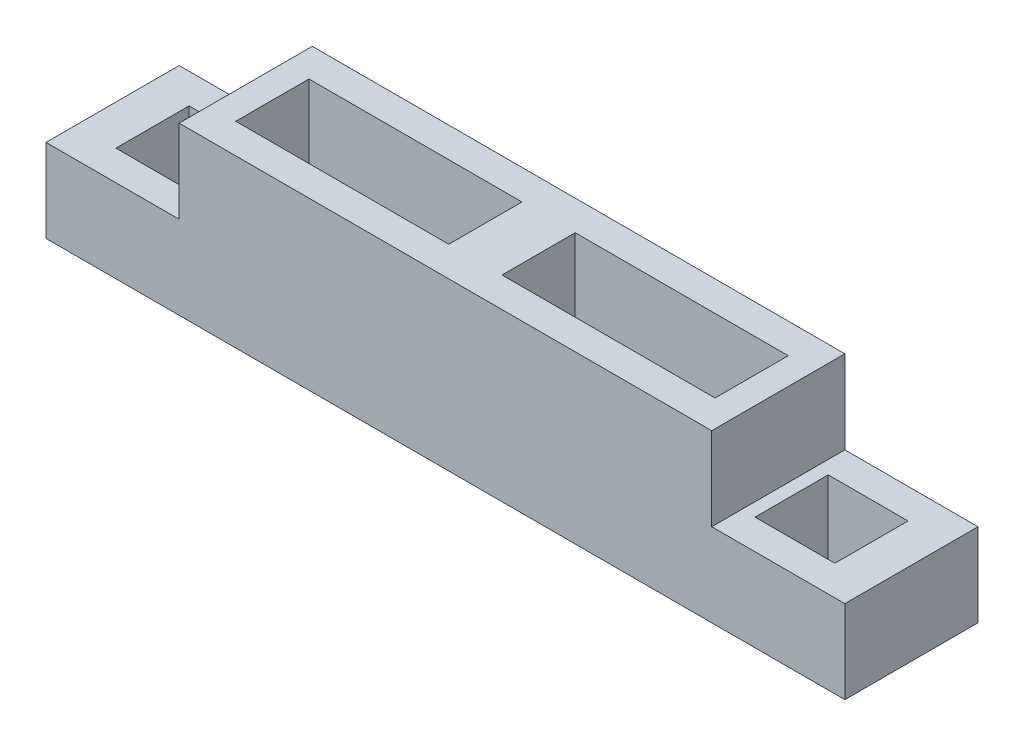
from build123d import *

# Parameters (mm, degrees)
SKETCH_1_W          = 1200
SKETCH_1_H          = 200
SKETCH_1_W_2        = 120
SKETCH_1_H_2        = 110
SKETCH_1_W_3        = 320
EXTRUDE_1_DEPTH     = 250
SKETCH_2_W          = 200
SKETCH_2_H          = 125
CUT_EXTRUDE_1_DEPTH = 201


with BuildPart() as part:
    # Эскиз1 → Бобышка-Вытянуть1 (new body)
    with BuildSketch(Plane(origin=(0, 0, 0), x_dir=(1, 0, 0), z_dir=(0, 1, 0))):
        Rectangle(SKETCH_1_W, SKETCH_1_H)
        with Locations((-480, 0)):
            Rectangle(SKETCH_1_W_2, SKETCH_1_H_2, mode=Mode.SUBTRACT)
        with Locations((-200, 0)):
            Rectangle(SKETCH_1_W_3, SKETCH_1_H_2, mode=Mode.SUBTRACT)
        with Locations((200, 0)):
            Rectangle(SKETCH_1_W_3, SKETCH_1_H_2, mode=Mode.SUBTRACT)
        with Locations((480, 0)):
            Rectangle(SKETCH_1_W_2, SKETCH_1_H_2, mode=Mode.SUBTRACT)
    extrude(amount=EXTRUDE_1_DEPTH)

    # Эскиз2 → Вырез-Вытянуть1 (cut, through all)
    with BuildSketch(Plane.XY.offset(100)):
        with Locations((-500, 187.5)):
            Rectangle(SKETCH_2_W, SKETCH_2_H)
        with Locations((500, 187.5)):
            Rectangle(SKETCH_2_W, SKETCH_2_H)
    extrude(amount=-CUT_EXTRUDE_1_DEPTH, mode=Mode.SUBTRACT)


solid = part.part
